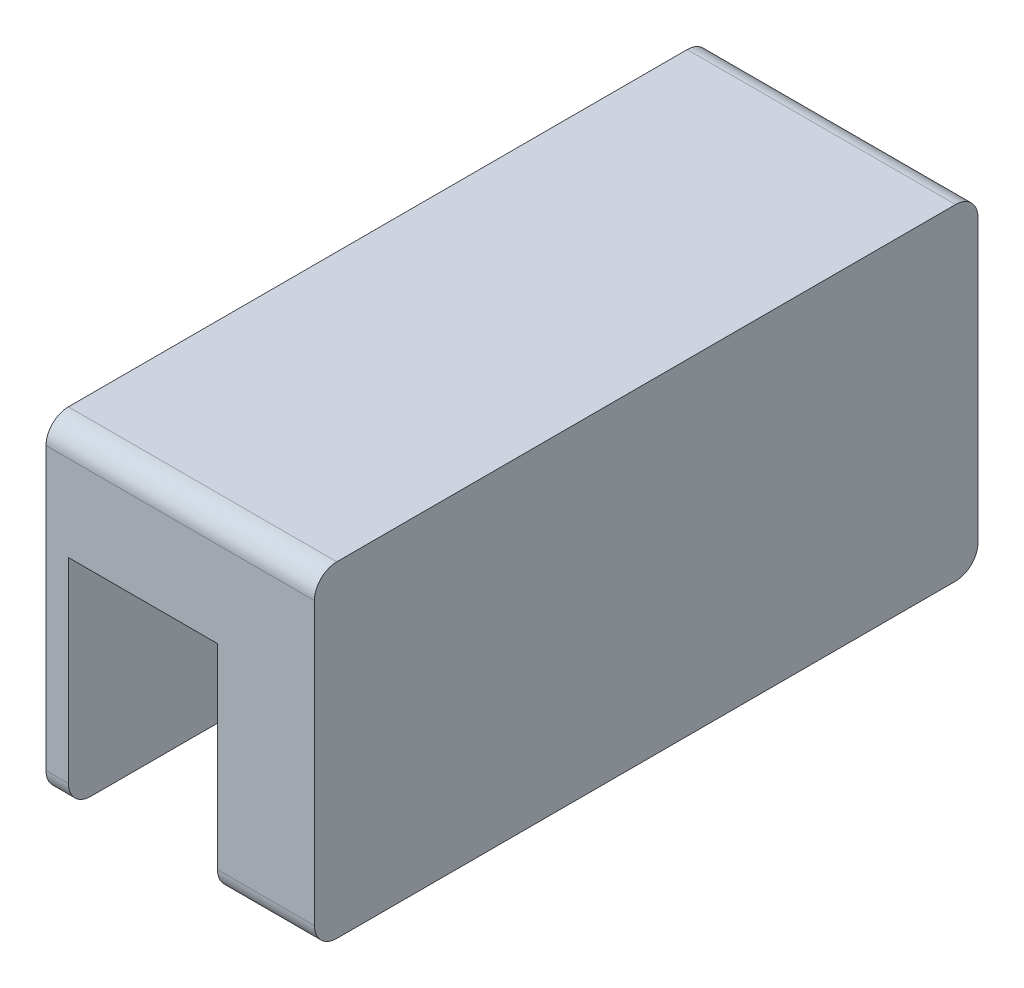
from build123d import *

# Parameters (mm, degrees)
RESSALTO_EXTRUS_O2_DEPTH      = 30
RESSALTO_EXTRUS_O3_DEPTH      = 3
RESSALTO_EXTRUS_O4_DEPTH      = 3
RESSALTO_EXTRUS_O4_DEPTH_BACK = 10


with BuildPart() as part:
    # Esboço2 → Ressalto-extrusão2 (new body)
    with BuildSketch(Plane(origin=(0, 0, 0), x_dir=(0, 0, -1), z_dir=(1, 0, 0))):
        with BuildLine():
            Line((2.90159992, -0.062465938), (-35.09840008, -0.062465938))
            Line((-35.09840008, -0.062465938), (-39.886084903, -0.062465938))
            ThreePointArc((-39.886084903, -0.062465938), (-45.202180234, 1.467638524), (-48.891439328, 5.589707975))
            ThreePointArc((-48.891439328, 5.589707975), (-52.096536948, 9.772081499), (-56.69840008, 12.338743681))
            ThreePointArc((-56.69840008, 12.338743681), (-59.373224015, 11.895603401), (-60.59840008, 9.476926077))
            Line((-60.59840008, 9.476926077), (-60.59840008, 20.976926077))
            ThreePointArc((-60.59840008, 20.976926077), (-59.719720424, 23.09824642), (-57.59840008, 23.976926077))
            Line((-57.59840008, 23.976926077), (25.40159992, 23.976926077))
            ThreePointArc((25.40159992, 23.976926077), (27.522920263, 23.09824642), (28.40159992, 20.976926077))
            Line((28.40159992, 20.976926077), (28.40159992, 9.476926077))
            ThreePointArc((28.40159992, 9.476926077), (27.176423855, 11.895603401), (24.50159992, 12.338743681))
            ThreePointArc((24.50159992, 12.338743681), (19.899736788, 9.772081499), (16.694639168, 5.589707975))
            ThreePointArc((16.694639168, 5.589707975), (13.005380073, 1.467638524), (7.689284743, -0.062465938))
            Line((7.689284743, -0.062465938), (2.90159992, -0.062465938))
        make_face()
    extrude(amount=RESSALTO_EXTRUS_O2_DEPTH)

    # Esboço3 → Ressalto-extrusão3 (add)
    with BuildSketch(Plane.ZY):
        with BuildLine():
            Line((60.59840008, 15.226926077), (60.59840008, 20.976926077))
            ThreePointArc((60.59840008, 20.976926077), (59.719720424, 23.09824642), (57.59840008, 23.976926077))
            Line((57.59840008, 23.976926077), (16.09840008, 23.976926077))
            Line((16.09840008, 23.976926077), (-25.40159992, 23.976926077))
            ThreePointArc((-25.40159992, 23.976926077), (-27.522920263, 23.09824642), (-28.40159992, 20.976926077))
            Line((-28.40159992, 20.976926077), (-28.40159992, 15.226926077))
            Line((-28.40159992, 15.226926077), (-28.40159992, -16.773073923))
            ThreePointArc((-28.40159992, -16.773073923), (-27.522920263, -18.894394267), (-25.40159992, -19.773073923))
            Line((-25.40159992, -19.773073923), (57.59840008, -19.773073923))
            ThreePointArc((57.59840008, -19.773073923), (59.719720424, -18.894394267), (60.59840008, -16.773073923))
            Line((60.59840008, -16.773073923), (60.59840008, 15.226926077))
        make_face()
    extrude(amount=RESSALTO_EXTRUS_O3_DEPTH)

    # Esboço4 → Ressalto-extrusão4 (add, two sides)
    with BuildSketch(Plane(origin=(30, 0, 0), x_dir=(0, 0, -1), z_dir=(1, 0, 0))) as ressalto_extrus_o4_sk:
        with BuildLine():
            Line((-16.09840008, 23.976926077), (25.40159992, 23.976926077))
            ThreePointArc((25.40159992, 23.976926077), (27.522920263, 23.09824642), (28.40159992, 20.976926077))
            Line((28.40159992, 20.976926077), (28.40159992, 15.226926077))
            Line((28.40159992, 15.226926077), (28.40159992, -16.773073923))
            ThreePointArc((28.40159992, -16.773073923), (27.522920263, -18.894394267), (25.40159992, -19.773073923))
            Line((25.40159992, -19.773073923), (-57.59840008, -19.773073923))
            ThreePointArc((-57.59840008, -19.773073923), (-59.719720424, -18.894394267), (-60.59840008, -16.773073923))
            Line((-60.59840008, -16.773073923), (-60.59840008, 15.226926077))
            Line((-60.59840008, 15.226926077), (-60.59840008, 20.976926077))
            ThreePointArc((-60.59840008, 20.976926077), (-59.719720424, 23.09824642), (-57.59840008, 23.976926077))
            Line((-57.59840008, 23.976926077), (-16.09840008, 23.976926077))
        make_face()
    extrude(amount=RESSALTO_EXTRUS_O4_DEPTH)
    extrude(ressalto_extrus_o4_sk.sketch, amount=-RESSALTO_EXTRUS_O4_DEPTH_BACK)


solid = part.part
